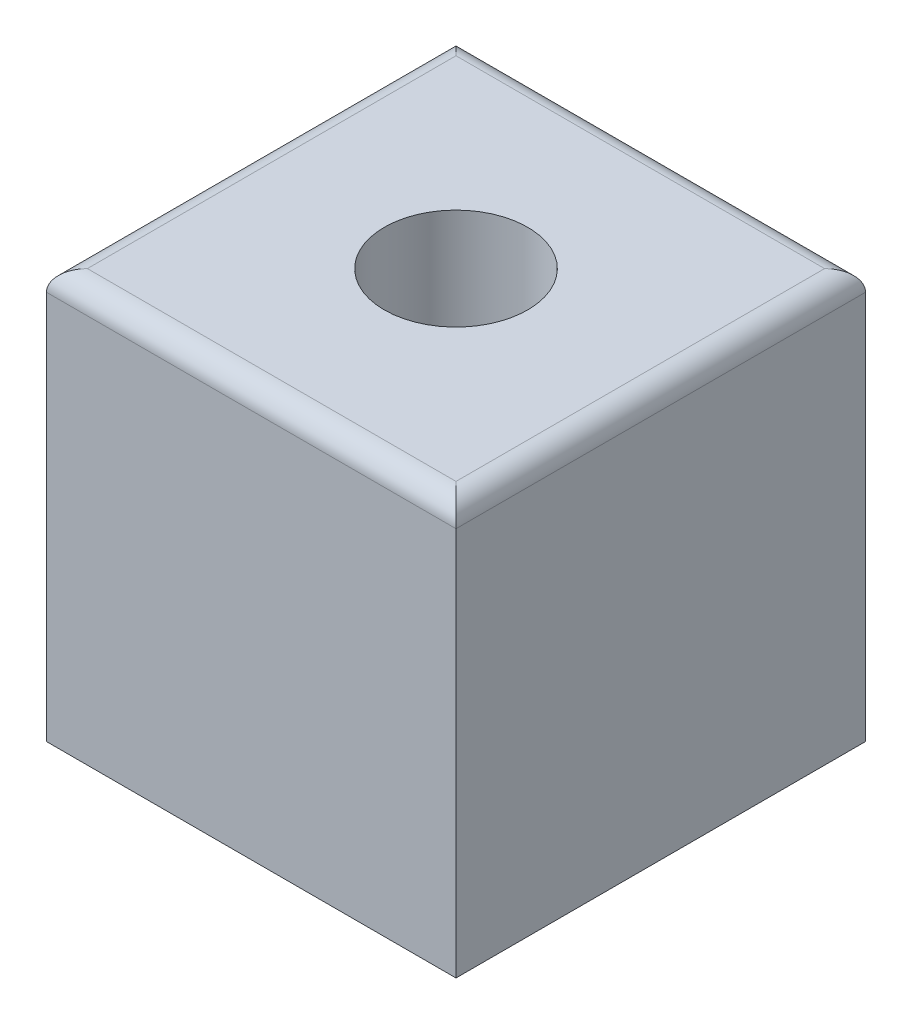
from build123d import *

# Parameters (mm, degrees)
SKETCH2_W           = 254
SKETCH2_H           = 254
BOSS_EXTRUDE1_DEPTH = 127
SKETCH3_R           = 44.45
CUT_EXTRUDE1_DEPTH  = 82.55
FILLET1_R           = 12.7


with BuildPart() as part:
    # Sketch2 → Boss-Extrude1 (new body, symmetric)
    with BuildSketch(Plane.XY):
        Rectangle(SKETCH2_W, SKETCH2_H)
    extrude(amount=BOSS_EXTRUDE1_DEPTH, both=True)

    # Sketch3 → Cut-Extrude1 (cut)
    with BuildSketch(Plane(origin=(0, 127, 0), x_dir=(1, 0, 0), z_dir=(0, 1, 0))):
        Circle(SKETCH3_R)
    extrude(amount=-CUT_EXTRUDE1_DEPTH, mode=Mode.SUBTRACT)

    # Fillet1
    fillet1_edges = [part.edges().sort_by_distance(p)[0] for p in [
        (0, 127, 127),
        (0, 127, -127),
        (-127, 127, 0),
        (127, 127, 0),
    ]]
    fillet(fillet1_edges, radius=FILLET1_R)


solid = part.part
